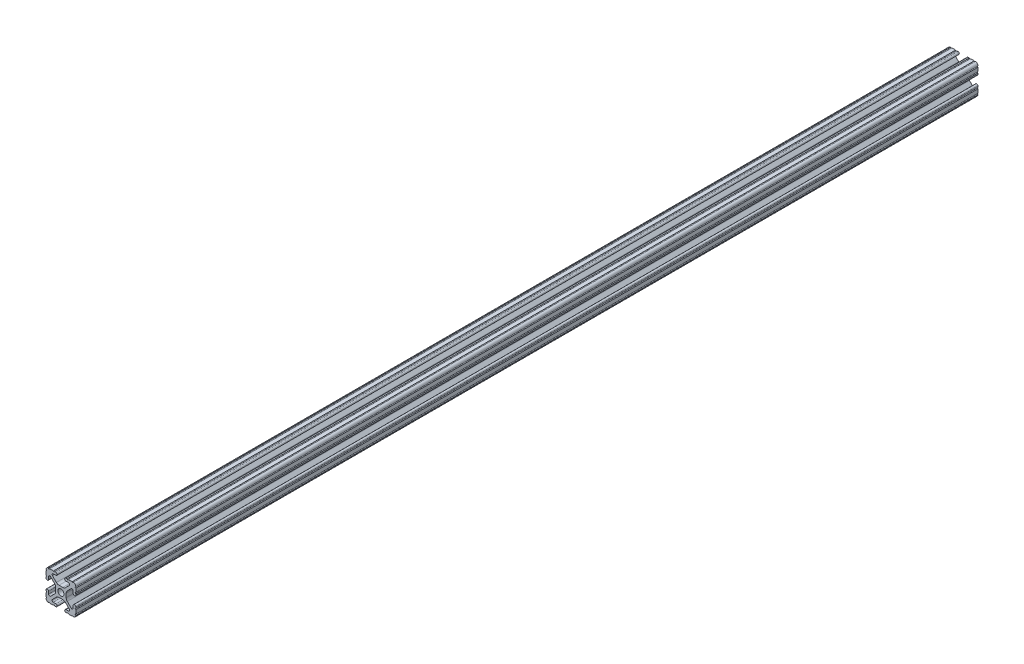
from build123d import *

# Parameters (mm, degrees)
SKETCH1_R           = 2.6035
BOSS_EXTRUDE1_DEPTH = 768.35


with BuildPart() as part:
    # Sketch1 → Boss-Extrude1 (new body)
    with BuildSketch(Plane(origin=(0, 0, -450.85), x_dir=(-1, 0, 0), z_dir=(0, 0, -1))):
        with BuildLine():
            Line((12.7, -9.5504), (12.7, -6.3330836))
            ThreePointArc((12.7, -6.3330836), (12.192, -5.8250836), (12.7, -5.3170836))
            Line((12.7, -5.3170836), (12.7, -4.3434))
            ThreePointArc((12.7, -4.3434), (11.5951, -3.2385), (10.4902, -4.3434))
            Line((10.4902, -4.3434), (10.4902, -6.474794456))
            ThreePointArc((10.4902, -6.474794456), (9.863006367, -7.413456061), (8.75577951, -7.193214945))
            Line((8.75577951, -7.193214945), (5.42573597, -3.863171405))
            ThreePointArc((5.42573597, -3.863171405), (4.737482484, -2.833127272), (4.4958, -1.618107374))
            Line((4.4958, -1.618107374), (4.4958, 1.618107374))
            ThreePointArc((4.4958, 1.618107374), (4.737482484, 2.833127272), (5.42573597, 3.863171405))
            Line((5.42573597, 3.863171405), (8.75577951, 7.193214945))
            ThreePointArc((8.75577951, 7.193214945), (9.863006367, 7.413456061), (10.4902, 6.474794456))
            Line((10.4902, 6.474794456), (10.4902, 4.343399971))
            ThreePointArc((10.4902, 4.343399971), (11.5951, 3.238499971), (12.7, 4.343399971))
            Line((12.7, 4.343399971), (12.7, 5.3170836))
            ThreePointArc((12.7, 5.3170836), (12.192, 5.8250836), (12.7, 6.3330836))
            Line((12.7, 6.3330836), (12.7, 9.5504))
            ThreePointArc((12.7, 9.5504), (12.192000006, 10.058323491), (12.699846982, 10.566399977))
            ThreePointArc((12.699846982, 10.566399977), (12.082522516, 12.082522516), (10.566399977, 12.699846982))
            ThreePointArc((10.566399977, 12.699846982), (10.058323491, 12.192000006), (9.5504, 12.7))
            Line((9.5504, 12.7), (6.3330836, 12.7))
            ThreePointArc((6.3330836, 12.7), (5.8250836, 12.192), (5.3170836, 12.7))
            Line((5.3170836, 12.7), (4.3434, 12.7))
            ThreePointArc((4.3434, 12.7), (3.2385, 11.5951), (4.3434, 10.4902))
            Line((4.3434, 10.4902), (6.474794456, 10.4902))
            ThreePointArc((6.474794456, 10.4902), (7.413456061, 9.863006367), (7.193214945, 8.75577951))
            Line((7.193214945, 8.75577951), (3.863171405, 5.42573597))
            ThreePointArc((3.863171405, 5.42573597), (2.833127272, 4.737482484), (1.618107374, 4.4958))
            Line((1.618107374, 4.4958), (-1.618107374, 4.4958))
            ThreePointArc((-1.618107374, 4.4958), (-2.833127272, 4.737482484), (-3.863171405, 5.42573597))
            Line((-3.863171405, 5.42573597), (-7.193214945, 8.75577951))
            ThreePointArc((-7.193214945, 8.75577951), (-7.413456061, 9.863006367), (-6.474794456, 10.4902))
            Line((-6.474794456, 10.4902), (-4.343399971, 10.4902))
            ThreePointArc((-4.343399971, 10.4902), (-3.238499971, 11.5951), (-4.343399971, 12.7))
            Line((-4.343399971, 12.7), (-5.3170836, 12.7))
            ThreePointArc((-5.3170836, 12.7), (-5.8250836, 12.192), (-6.3330836, 12.7))
            Line((-6.3330836, 12.7), (-9.5504, 12.7))
            ThreePointArc((-9.5504, 12.7), (-10.058323491, 12.192000006), (-10.566399977, 12.699846982))
            ThreePointArc((-10.566399977, 12.699846982), (-12.082522516, 12.082522516), (-12.699846982, 10.566399977))
            ThreePointArc((-12.699846982, 10.566399977), (-12.192000006, 10.058323491), (-12.7, 9.5504))
            Line((-12.7, 9.5504), (-12.7, 6.3330836))
            ThreePointArc((-12.7, 6.3330836), (-12.192, 5.8250836), (-12.7, 5.3170836))
            Line((-12.7, 5.3170836), (-12.7, 4.3434))
            ThreePointArc((-12.7, 4.3434), (-11.5951, 3.2385), (-10.4902, 4.3434))
            Line((-10.4902, 4.3434), (-10.4902, 6.474794456))
            ThreePointArc((-10.4902, 6.474794456), (-9.863006367, 7.413456061), (-8.75577951, 7.193214945))
            Line((-8.75577951, 7.193214945), (-5.42573597, 3.863171405))
            ThreePointArc((-5.42573597, 3.863171405), (-4.737482484, 2.833127272), (-4.4958, 1.618107374))
            Line((-4.4958, 1.618107374), (-4.4958, -1.618107374))
            ThreePointArc((-4.4958, -1.618107374), (-4.737482484, -2.833127272), (-5.42573597, -3.863171405))
            Line((-5.42573597, -3.863171405), (-8.75577951, -7.193214945))
            ThreePointArc((-8.75577951, -7.193214945), (-9.863006367, -7.413456061), (-10.4902, -6.474794456))
            Line((-10.4902, -6.474794456), (-10.4902, -4.343399971))
            ThreePointArc((-10.4902, -4.343399971), (-11.5951, -3.238499971), (-12.7, -4.343399971))
            Line((-12.7, -4.343399971), (-12.7, -5.3170836))
            ThreePointArc((-12.7, -5.3170836), (-12.192, -5.8250836), (-12.7, -6.3330836))
            Line((-12.7, -6.3330836), (-12.7, -9.5504))
            ThreePointArc((-12.7, -9.5504), (-12.192000006, -10.058323491), (-12.699846982, -10.566399977))
            ThreePointArc((-12.699846982, -10.566399977), (-12.082522516, -12.082522516), (-10.566399977, -12.699846982))
            ThreePointArc((-10.566399977, -12.699846982), (-10.058323491, -12.192000006), (-9.5504, -12.7))
            Line((-9.5504, -12.7), (-6.3330836, -12.7))
            ThreePointArc((-6.3330836, -12.7), (-5.8250836, -12.192), (-5.3170836, -12.7))
            Line((-5.3170836, -12.7), (-4.3434, -12.7))
            ThreePointArc((-4.3434, -12.7), (-3.2385, -11.5951), (-4.3434, -10.4902))
            Line((-4.3434, -10.4902), (-6.474794456, -10.4902))
            ThreePointArc((-6.474794456, -10.4902), (-7.413456061, -9.863006367), (-7.193214945, -8.75577951))
            Line((-7.193214945, -8.75577951), (-3.863171405, -5.42573597))
            ThreePointArc((-3.863171405, -5.42573597), (-2.833127272, -4.737482484), (-1.618107374, -4.4958))
            Line((-1.618107374, -4.4958), (1.618107374, -4.4958))
            ThreePointArc((1.618107374, -4.4958), (2.833127272, -4.737482484), (3.863171405, -5.42573597))
            Line((3.863171405, -5.42573597), (7.193214945, -8.75577951))
            ThreePointArc((7.193214945, -8.75577951), (7.413456061, -9.863006367), (6.474794456, -10.4902))
            Line((6.474794456, -10.4902), (4.343399971, -10.4902))
            ThreePointArc((4.343399971, -10.4902), (3.238499971, -11.5951), (4.343399971, -12.7))
            Line((4.343399971, -12.7), (5.3170836, -12.7))
            ThreePointArc((5.3170836, -12.7), (5.8250836, -12.192), (6.3330836, -12.7))
            Line((6.3330836, -12.7), (9.5504, -12.7))
            ThreePointArc((9.5504, -12.7), (10.058323491, -12.192000006), (10.566399977, -12.699846982))
            ThreePointArc((10.566399977, -12.699846982), (12.082522516, -12.082522516), (12.699846982, -10.566399977))
            ThreePointArc((12.699846982, -10.566399977), (12.192000006, -10.058323491), (12.7, -9.5504))
        make_face()
        Circle(SKETCH1_R, mode=Mode.SUBTRACT)
    extrude(amount=-BOSS_EXTRUDE1_DEPTH)


solid = part.part
